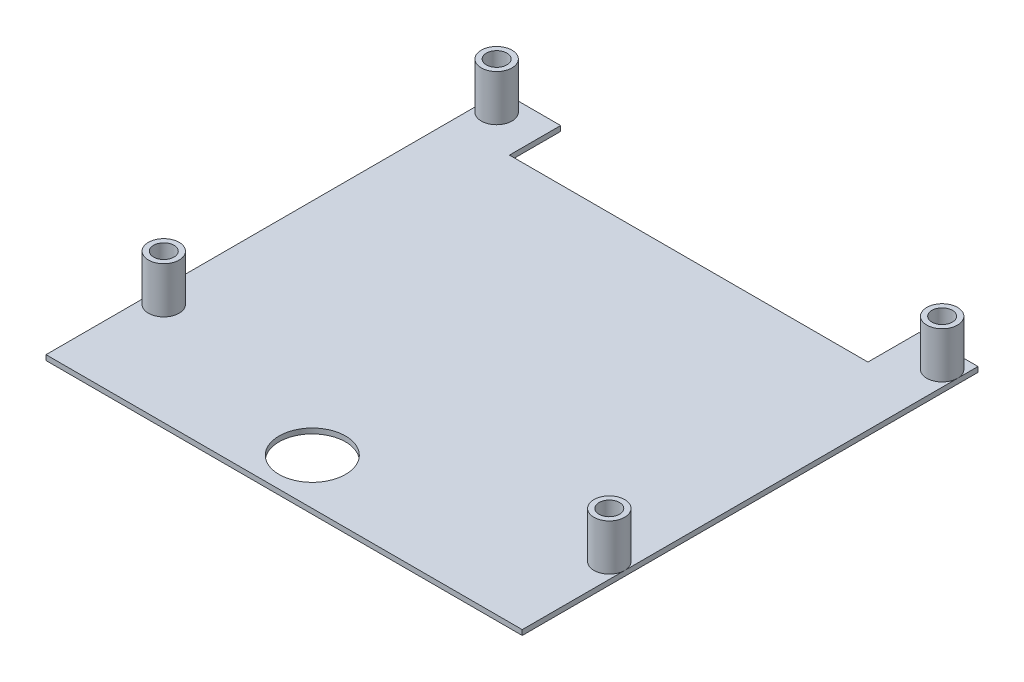
from build123d import *

# Parameters (mm, degrees)
SKETCH1_W           = 93
SKETCH1_H           = 89
BOSS_EXTRUDE1_DEPTH = 1
SKETCH2_R           = 3
BOSS_EXTRUDE2_DEPTH = 9
SKETCH3_R           = 6.5
SKETCH3_W           = 70
SKETCH3_H           = 10
CUT_EXTRUDE4_DEPTH  = 1
SKETCH4_R           = 2
CUT_EXTRUDE5_DEPTH  = 10


with BuildPart() as part:
    # Sketch1 → Boss-Extrude1 (new body)
    with BuildSketch(Plane(origin=(0, 0, 0), x_dir=(1, 0, 0), z_dir=(0, 1, 0))):
        Rectangle(SKETCH1_W, SKETCH1_H)
    extrude(amount=BOSS_EXTRUDE1_DEPTH)

    # Sketch2 → Boss-Extrude2 (add)
    with BuildSketch(Plane(origin=(0, 1, 0), x_dir=(1, 0, 0), z_dir=(0, 1, 0))):
        with Locations((-43.5, 40.5)):
            Circle(SKETCH2_R)
        with Locations((43.5, 40.5)):
            Circle(SKETCH2_R)
        with Locations((-43.5, -24.5)):
            Circle(SKETCH2_R)
        with Locations((43.5, -24.5)):
            Circle(SKETCH2_R)
    extrude(amount=BOSS_EXTRUDE2_DEPTH)

    # Sketch3 → Cut-Extrude4 (cut)
    with BuildSketch(Plane(origin=(0, 1, 0), x_dir=(1, 0, 0), z_dir=(0, 1, 0))):
        with Locations((-3.5, -35.5)):
            Circle(SKETCH3_R)
        with Locations((0, 39.5)):
            Rectangle(SKETCH3_W, SKETCH3_H)
    extrude(amount=-CUT_EXTRUDE4_DEPTH, mode=Mode.SUBTRACT)

    # Sketch4 → Cut-Extrude5 (cut)
    with BuildSketch(Plane(origin=(0, 10, 0), x_dir=(1, 0, 0), z_dir=(0, 1, 0))):
        with Locations((-43.5, 40.5)):
            Circle(SKETCH4_R)
        with Locations((-43.5, -24.5)):
            Circle(SKETCH4_R)
        with Locations((43.5, 40.5)):
            Circle(SKETCH4_R)
        with Locations((43.5, -24.5)):
            Circle(SKETCH4_R)
    extrude(amount=-CUT_EXTRUDE5_DEPTH, mode=Mode.SUBTRACT)


solid = part.part
